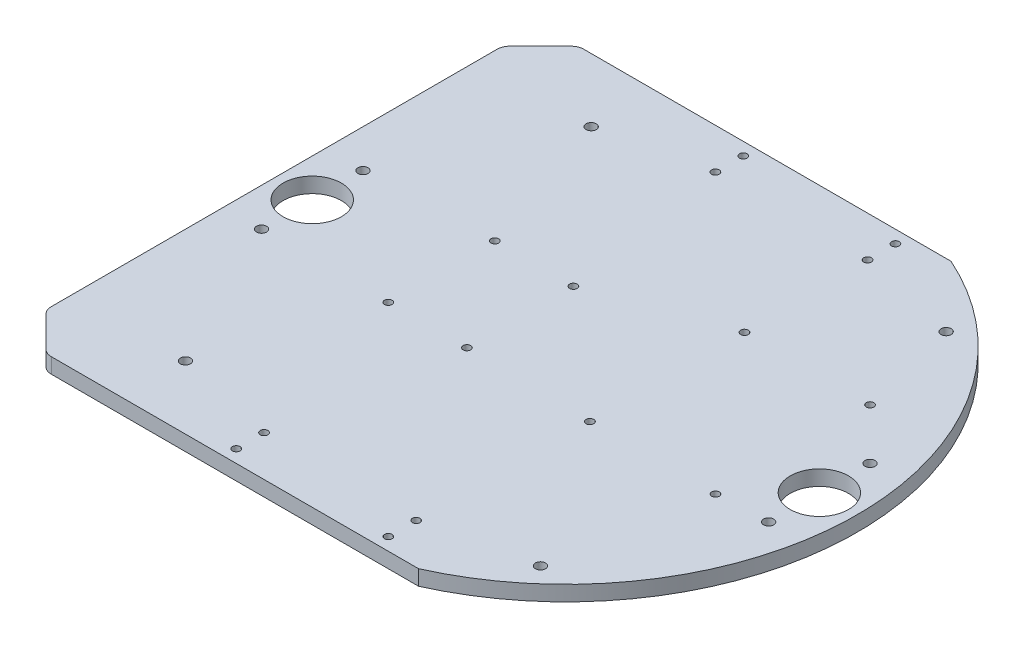
from build123d import *

# Parameters (mm, degrees)
SKETCH1_R           = 1.5
BOSS_EXTRUDE2_DEPTH = 6
SKETCH2_R           = 1.5
SKETCH2_R_2         = 2
SKETCH2_R_3         = 11.5
CUT_EXTRUDE1_DEPTH  = 6
BOSS_EXTRUDE3_DEPTH = 6
CHAMFER1_SIZE       = 15
FILLET1_R           = 5


with BuildPart() as part:
    # Sketch1 → Boss-Extrude2 (new body)
    with BuildSketch(Plane(origin=(0, 0, 0), x_dir=(1, 0, 0), z_dir=(0, 1, 0))):
        with BuildLine():
            Line((-46.904157598, -105), (46.904157598, -105))
            ThreePointArc((46.904157598, -105), (115, 0), (46.904157598, 105))
            Line((46.904157598, 105), (-46.904157598, 105))
            ThreePointArc((-46.904157598, 105), (-115, 0), (-46.904157598, -105))
        make_face()
        with Locations((-30, 100)):
            Circle(SKETCH1_R, mode=Mode.SUBTRACT)
        with Locations((30, 100)):
            Circle(SKETCH1_R, mode=Mode.SUBTRACT)
        with Locations((30, 89)):
            Circle(SKETCH1_R, mode=Mode.SUBTRACT)
        with Locations((-30, 89)):
            Circle(SKETCH1_R, mode=Mode.SUBTRACT)
        with Locations((-30, -89)):
            Circle(SKETCH1_R, mode=Mode.SUBTRACT)
        with Locations((30, -89)):
            Circle(SKETCH1_R, mode=Mode.SUBTRACT)
        with Locations((30, -100)):
            Circle(SKETCH1_R, mode=Mode.SUBTRACT)
        with Locations((-30, -100)):
            Circle(SKETCH1_R, mode=Mode.SUBTRACT)
    extrude(amount=BOSS_EXTRUDE2_DEPTH)

    # Sketch2 → Cut-Extrude1 (cut)
    with BuildSketch(Plane(origin=(0, 6, 0), x_dir=(1, 0, 0), z_dir=(0, 1, 0))):
        with Locations((-50, 22)):
            Circle(SKETCH2_R)
        with Locations((-19, 22)):
            Circle(SKETCH2_R)
        with Locations((-19, -20)):
            Circle(SKETCH2_R)
        with Locations((-50, -20)):
            Circle(SKETCH2_R)
        with Locations((80, 40)):
            Circle(SKETCH2_R)
        with Locations((30.47, 40)):
            Circle(SKETCH2_R)
        with Locations((30.47, -20.96)):
            Circle(SKETCH2_R)
        with Locations((80, -20.96)):
            Circle(SKETCH2_R)
        with Locations((70, 80)):
            Circle(SKETCH2_R_2)
        with Locations((-70, 80)):
            Circle(SKETCH2_R_2)
        with Locations((-70, -80)):
            Circle(SKETCH2_R_2)
        with Locations((70, -80)):
            Circle(SKETCH2_R_2)
        with Locations((-100, 20)):
            Circle(SKETCH2_R_2)
        with Locations((-100, -20)):
            Circle(SKETCH2_R_2)
        with Locations((100, 20)):
            Circle(SKETCH2_R_2)
        with Locations((100, -20)):
            Circle(SKETCH2_R_2)
        with Locations((-100, 0)):
            Circle(SKETCH2_R_3)
        with Locations((100, 0)):
            Circle(SKETCH2_R_3)
    extrude(amount=-CUT_EXTRUDE1_DEPTH, mode=Mode.SUBTRACT)

    # Sketch4 → Boss-Extrude3 (add)
    with BuildSketch(Plane(origin=(0, 6, 0), x_dir=(1, 0, 0), z_dir=(0, 1, 0))):
        with BuildLine():
            ThreePointArc((-115, 0), (-96.485693561, 62.574043645), (-46.904157598, 105))
            Line((-46.904157598, 105), (-115, 105))
            Line((-115, 105), (-115, 0))
        make_face()
        with BuildLine():
            ThreePointArc((-46.904157598, -105), (-96.485693561, -62.574043645), (-115, 0))
            Line((-115, 0), (-115, -105))
            Line((-115, -105), (-46.904157598, -105))
        make_face()
    extrude(amount=-BOSS_EXTRUDE3_DEPTH)

    # Chamfer1
    chamfer1_edges = [part.edges().sort_by_distance(p)[0] for p in [
        (-115, 3, -105),
        (-115, 3, 105),
    ]]
    chamfer(chamfer1_edges, length=CHAMFER1_SIZE)

    # Fillet1
    fillet1_edges = [part.edges().sort_by_distance(p)[0] for p in [
        (-115, 3, -90),
        (-115, 3, 90),
        (-100, 3, 105),
        (-100, 3, -105),
    ]]
    fillet(fillet1_edges, radius=FILLET1_R)


solid = part.part
